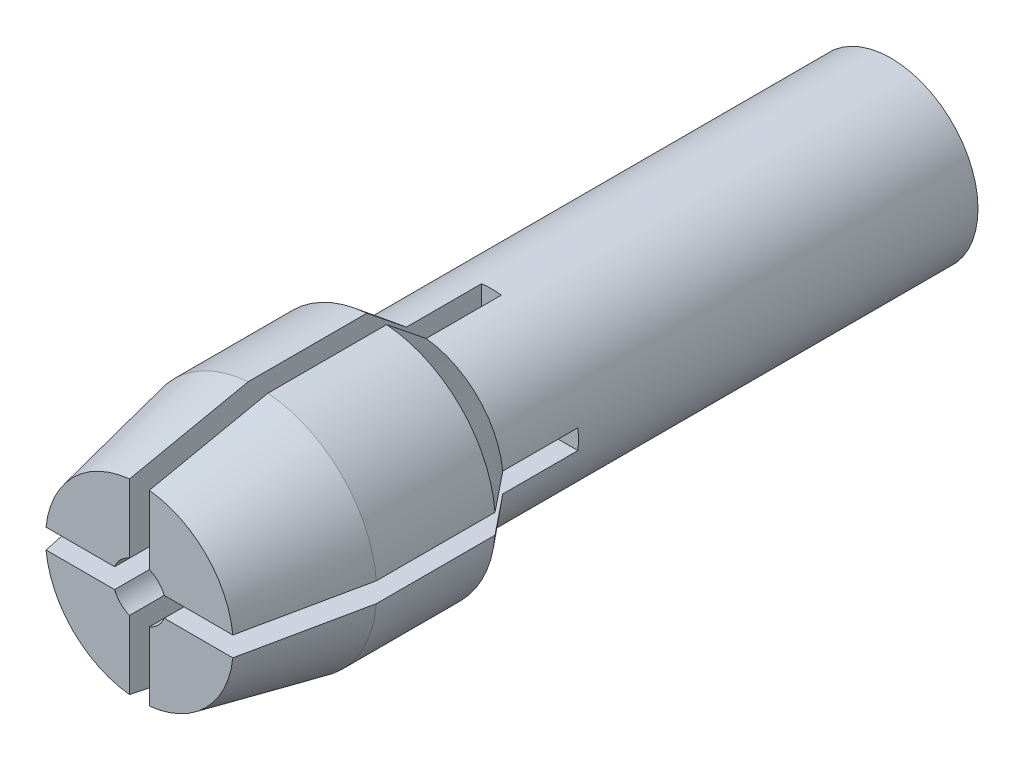
from build123d import *

# Parameters (mm, degrees)
SKETCH1_R           = 2.2
SKETCH1_R_2         = 1.25
BOSS_EXTRUDE1_DEPTH = 12
SKETCH2_R           = 3
SKETCH2_R_2         = 0.675
BOSS_EXTRUDE2_DEPTH = 7
CUT_EXTRUDE1_DEPTH  = 8.9


with BuildPart() as part:
    # Sketch1 → Boss-Extrude1 (new body)
    with BuildSketch(Plane.XY):
        Circle(SKETCH1_R)
        Circle(SKETCH1_R_2, mode=Mode.SUBTRACT)
    extrude(amount=BOSS_EXTRUDE1_DEPTH)

    # Sketch2 → Boss-Extrude2 (add)
    with BuildSketch(Plane.XY.offset(12)):
        Circle(SKETCH2_R)
        Circle(SKETCH2_R_2, mode=Mode.SUBTRACT)
    extrude(amount=BOSS_EXTRUDE2_DEPTH)

    # Sketch3 → Cut-Revolve1 (revolve, cut)
    with BuildSketch(Plane(origin=(0, 0, 0), x_dir=(1, 0, 0), z_dir=(0, 1, 0))):
        Polygon((2.2, -12), (3, -13), (4.276308893, -12.361058563), (3.46784885, -11.152134436), align=None)
        Polygon((2.375, -19), (3, -16), (5.751760011, -17.171813113), (4.254862661, -20.939605223), align=None)
    revolve(axis=Axis((0, 0, 0), (0, 0, 1)), mode=Mode.SUBTRACT)

    # Sketch4 → Cut-Extrude1 (cut)
    with BuildSketch(Plane.XY.offset(19)):
        Polygon((0, 3.340763125), (-0.25, 3.340763125), (-0.25, 0.464842209), (0.25, 0.464842209), (0.25, 3.340763125), align=None)
        Polygon((3.340763125, 0), (3.340763125, 0.25), (0.464842209, 0.25), (0.464842209, -0.25), (3.340763125, -0.25), align=None)
        Polygon((0, -3.340763125), (0.25, -3.340763125), (0.25, -0.464842209), (-0.25, -0.464842209), (-0.25, -3.340763125), align=None)
        Polygon((-3.340763125, 0), (-3.340763125, -0.25), (-0.464842209, -0.25), (-0.464842209, 0.25), (-3.340763125, 0.25), align=None)
    extrude(amount=-CUT_EXTRUDE1_DEPTH, mode=Mode.SUBTRACT)


solid = part.part
